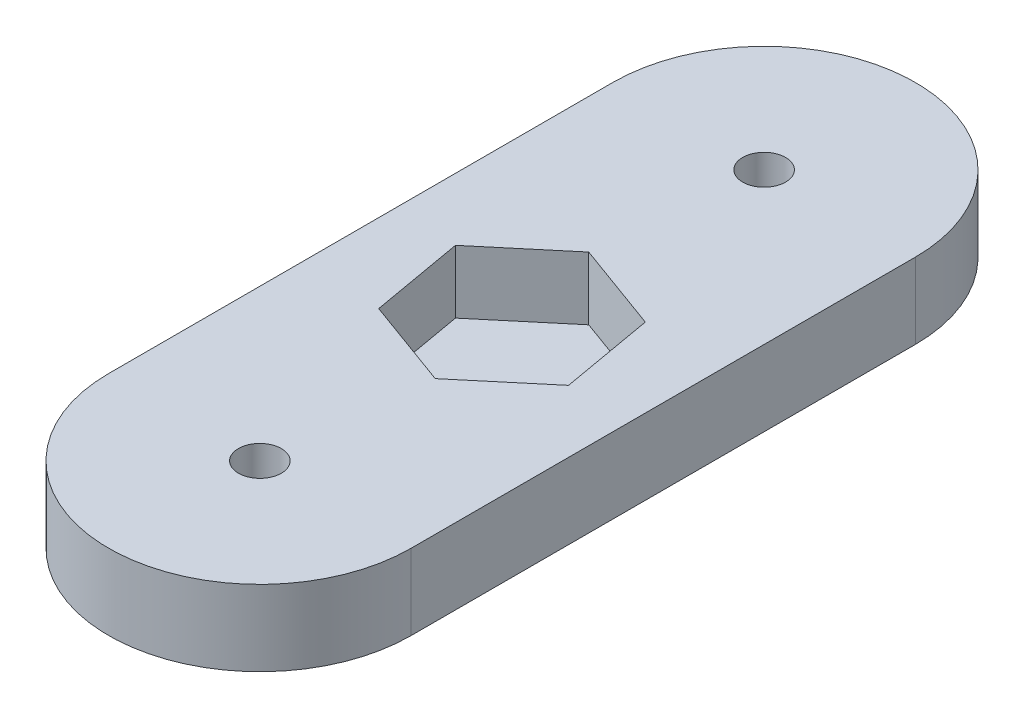
from build123d import *

# Parameters (mm, degrees)
SKETCH1_R           = 1.7
BOSS_EXTRUDE1_DEPTH = 6
CUT_EXTRUDE1_DEPTH  = 5


with BuildPart() as part:
    # Sketch1 → Boss-Extrude1 (new body)
    with BuildSketch(Plane(origin=(0, 0, 0), x_dir=(1, 0, 0), z_dir=(0, 1, 0))):
        with BuildLine():
            Line((-12, 0), (-12, 40))
            ThreePointArc((-12, 40), (0, 52), (12, 40))
            Line((12, 40), (12, 0))
            ThreePointArc((12, 0), (0, -12), (-12, 0))
        make_face()
        with Locations((0, 40)):
            Circle(SKETCH1_R, mode=Mode.SUBTRACT)
        Circle(SKETCH1_R, mode=Mode.SUBTRACT)
    extrude(amount=BOSS_EXTRUDE1_DEPTH)

    # Sketch2 → Cut-Extrude1 (cut)
    with BuildSketch(Plane(origin=(0, 6, 0), x_dir=(1, 0, 0), z_dir=(0, 1, 0))):
        Polygon((1.303325688, 12.608472723), (7.052913238, 17.432949516), (5.749587551, 24.824476793), (-1.303325688, 27.391527277), (-7.052913238, 22.567050484), (-5.749587551, 15.175523207), align=None)
    extrude(amount=-CUT_EXTRUDE1_DEPTH, mode=Mode.SUBTRACT)


solid = part.part
